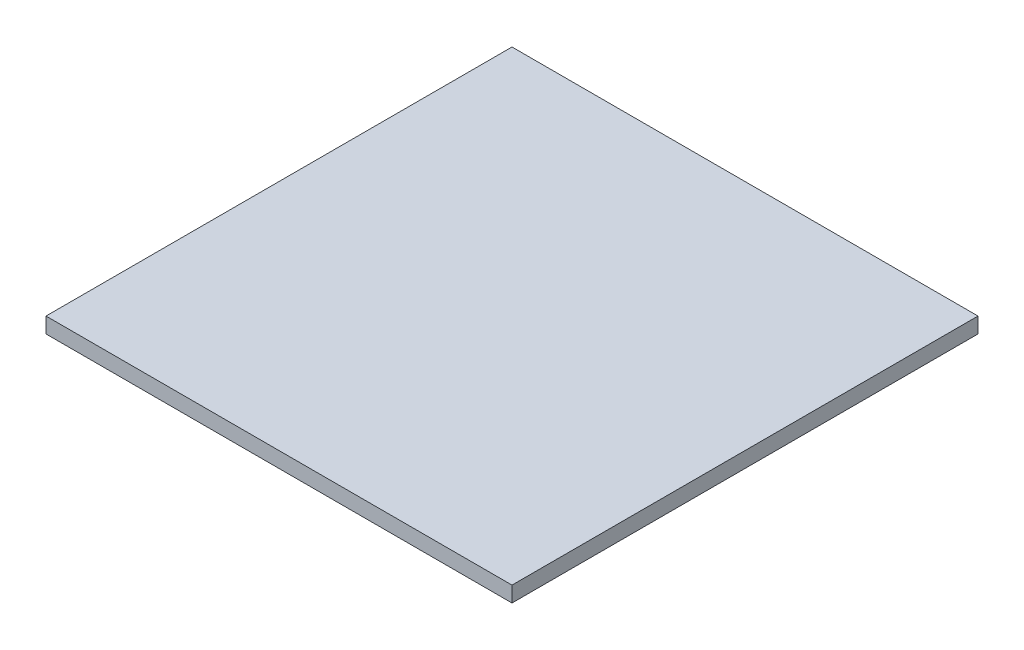
from build123d import *

# Parameters (mm, degrees)
SKETCH1_W           = 300
SKETCH1_H           = 300
BOSS_EXTRUDE1_DEPTH = 5


with BuildPart() as part:
    # Sketch1 → Boss-Extrude1 (new body, symmetric)
    with BuildSketch(Plane(origin=(0, 0, 0), x_dir=(1, 0, 0), z_dir=(0, 1, 0))):
        Rectangle(SKETCH1_W, SKETCH1_H)
    extrude(amount=BOSS_EXTRUDE1_DEPTH, both=True)


solid = part.part
